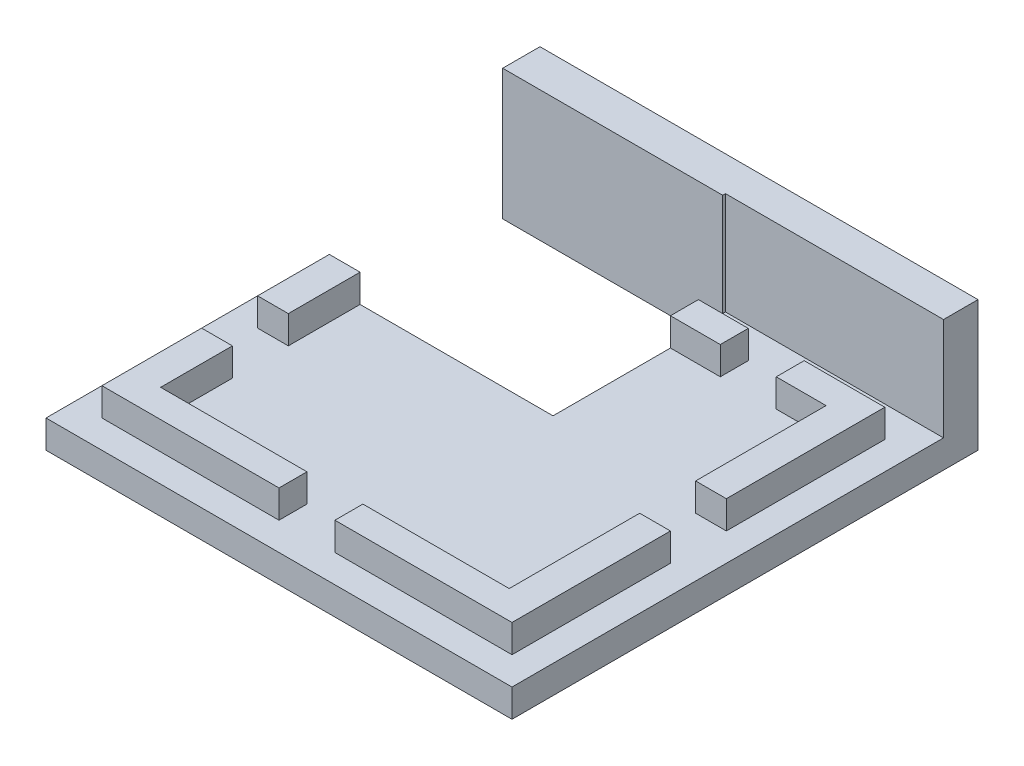
from build123d import *

# Parameters (mm, degrees)
SKETCH1_W               = 25
SKETCH1_H               = 23
BOSS_EXTRUDE1_DEPTH     = 1.5
SKETCH2_W               = 22
SKETCH2_H               = 20
SKETCH2_W_2             = 18.7
SKETCH2_H_2             = 17
BOSS_EXTRUDE2_DEPTH     = 1.5
SKETCH4_W               = 12
SKETCH4_H               = 7.8
CUT_EXTRUDE2_DEPTH      = 2.5
CUT_EXTRUDE2_DEPTH_BACK = 2.5
SKETCH5_W               = 13.5
SKETCH5_H               = 9.3
CUT_EXTRUDE3_DEPTH      = 4
SKETCH6_W               = 1.65
SKETCH6_H               = 3
SKETCH6_W_2             = 3
SKETCH6_H_2             = 1.5
CUT_EXTRUDE4_DEPTH      = 1.5
SKETCH7_W               = 23.5
SKETCH7_H               = 7
BOSS_EXTRUDE3_DEPTH     = 2
SKETCH8_W               = 11.7
SKETCH8_H               = 0.15
CUT_EXTRUDE5_DEPTH      = 5.5


with BuildPart() as part:
    # Sketch1 → Boss-Extrude1 (new body)
    with BuildSketch(Plane(origin=(0, 0, 0), x_dir=(1, 0, 0), z_dir=(0, 1, 0))):
        Rectangle(SKETCH1_W, SKETCH1_H)
    extrude(amount=BOSS_EXTRUDE1_DEPTH)

    # Sketch2 → Boss-Extrude2 (add)
    with BuildSketch(Plane(origin=(0, 1.5, 0), x_dir=(1, 0, 0), z_dir=(0, 1, 0))):
        Rectangle(SKETCH2_W, SKETCH2_H)
        Rectangle(SKETCH2_W_2, SKETCH2_H_2, mode=Mode.SUBTRACT)
    extrude(amount=BOSS_EXTRUDE2_DEPTH)

    # Sketch4 → Cut-Extrude2 (cut, two sides)
    with BuildSketch(Plane(origin=(0, 1.5, 0), x_dir=(1, 0, 0), z_dir=(0, 1, 0))) as cut_extrude2_sk:
        with Locations((-5, 6.1)):
            Rectangle(SKETCH4_W, SKETCH4_H)
    extrude(amount=CUT_EXTRUDE2_DEPTH, mode=Mode.SUBTRACT)
    extrude(cut_extrude2_sk.sketch, amount=-CUT_EXTRUDE2_DEPTH_BACK, mode=Mode.SUBTRACT)

    # Sketch5 → Cut-Extrude3 (cut, through all)
    with BuildSketch(Plane.XZ):
        with Locations((-5.75, -6.85)):
            Rectangle(SKETCH5_W, SKETCH5_H)
    extrude(amount=-CUT_EXTRUDE3_DEPTH, mode=Mode.SUBTRACT)

    # Sketch6 → Cut-Extrude4 (cut)
    with BuildSketch(Plane(origin=(0, 3, 0), x_dir=(1, 0, 0), z_dir=(0, 1, 0))):
        with Locations((-10.175, -3.15)):
            Rectangle(SKETCH6_W, SKETCH6_H)
        with Locations((0, -9.25)):
            Rectangle(SKETCH6_W_2, SKETCH6_H_2)
        with Locations((10.175, 0)):
            Rectangle(SKETCH6_W, SKETCH6_H)
        with Locations((5.175, 9.25)):
            Rectangle(SKETCH6_W_2, SKETCH6_H_2)
    extrude(amount=-CUT_EXTRUDE4_DEPTH, mode=Mode.SUBTRACT)

    # Sketch7 → Boss-Extrude3 (add)
    with BuildSketch(Plane(origin=(0, 0, -11.5), x_dir=(-1, 0, 0), z_dir=(0, 0, -1))):
        with Locations((-0.75, 3.5)):
            Rectangle(SKETCH7_W, SKETCH7_H)
    extrude(amount=BOSS_EXTRUDE3_DEPTH)

    # Sketch8 → Cut-Extrude5 (cut)
    with BuildSketch(Plane(origin=(0, 7, 0), x_dir=(1, 0, 0), z_dir=(0, 1, 0))):
        with Locations((6.65, 11.575)):
            Rectangle(SKETCH8_W, SKETCH8_H)
    extrude(amount=-CUT_EXTRUDE5_DEPTH, mode=Mode.SUBTRACT)


solid = part.part
